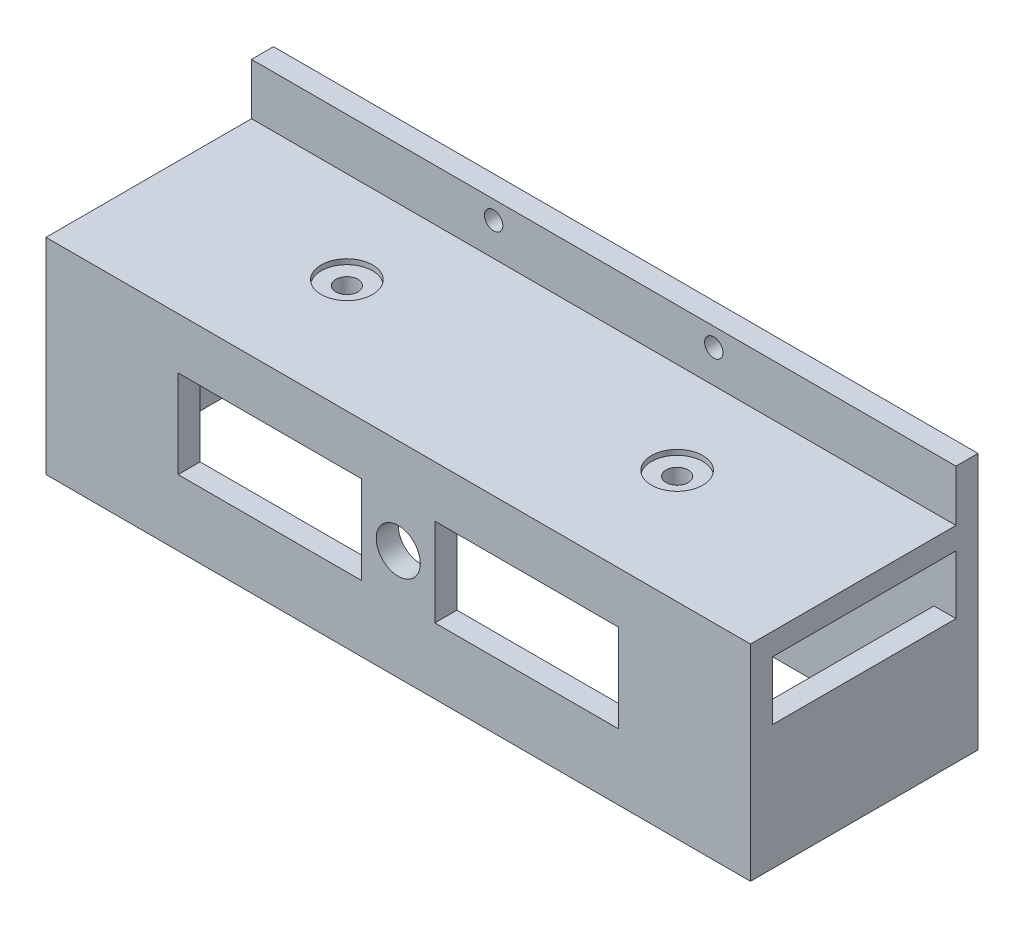
from build123d import *

# Parameters (mm, degrees)
SKETCH1_W           = 96
SKETCH1_H           = 28
BOSS_EXTRUDE1_DEPTH = 3
SKETCH2_W           = 3
SKETCH2_H           = 25
BOSS_EXTRUDE2_DEPTH = 25
SKETCH3_W           = 96
SKETCH3_H           = 35
BOSS_EXTRUDE3_DEPTH = 3
CUT_EXTRUDE2_REACH  = 30
SKETCH4_R           = 1.5
SKETCH5_R           = 3.5
CUT_EXTRUDE3_DEPTH  = 0.7
CUT_EXTRUDE4_REACH  = 33
SKETCH6_R           = 1.5
SKETCH6_R_2         = 1.25
SKETCH7_R           = 4
CUT_EXTRUDE5_DEPTH  = 2
CUT_EXTRUDE7_REACH  = 33
SKETCH8_R           = 3
SKETCH8_W           = 25
SKETCH8_H           = 12
CUT_EXTRUDE8_REACH  = 5
SKETCH9_W           = 20
SKETCH9_H           = 10
SKETCH9_W_2         = 9
CUT_EXTRUDE9_REACH  = 5
SKETCH10_W          = 25
SKETCH10_H          = 8


with BuildPart() as part:
    # Sketch1 → Boss-Extrude1 (new body)
    with BuildSketch(Plane(origin=(0, 0, 0), x_dir=(1, 0, 0), z_dir=(0, 1, 0))):
        with Locations((2.671135036, -161.861135542)):
            Rectangle(SKETCH1_W, SKETCH1_H)
    extrude(amount=BOSS_EXTRUDE1_DEPTH)

    # Sketch2 → Boss-Extrude2 (add)
    with BuildSketch(Plane(origin=(0, 0, 0), x_dir=(-1, 0, 0), z_dir=(0, -1, 0))):
        Polygon((-50.671135036, -175.861135542), (45.328864964, -175.861135542), (45.328864964, -172.861135542), (42.328864964, -172.861135542), (-47.671135036, -172.861135542), (-50.671135036, -172.861135542), align=None)
        with Locations((43.828864964, -160.361135542)):
            Rectangle(SKETCH2_W, SKETCH2_H)
        with Locations((-49.171135036, -160.361135542)):
            Rectangle(SKETCH2_W, SKETCH2_H)
    extrude(amount=BOSS_EXTRUDE2_DEPTH)

    # Sketch3 → Boss-Extrude3 (add)
    with BuildSketch(Plane(origin=(0, 0, 147.861135542), x_dir=(-1, 0, 0), z_dir=(0, 0, -1))):
        with Locations((-2.671135036, -7.5)):
            Rectangle(SKETCH3_W, SKETCH3_H)
    extrude(amount=BOSS_EXTRUDE3_DEPTH)

    # Sketch4 → Cut-Extrude2 (cut, up to next)
    with BuildSketch(Plane(origin=(0, 3, 0), x_dir=(1, 0, 0), z_dir=(0, 1, 0)), mode=Mode.PRIVATE) as cut_extrude2_sk1:
        with Locations((-19.828864964, -160.361135542)):
            Circle(SKETCH4_R)
    cut_extrude2_tool1 = extrude(cut_extrude2_sk1.sketch, amount=-CUT_EXTRUDE2_REACH, mode=Mode.PRIVATE) & part.part
    add(cut_extrude2_tool1.solids().sort_by_distance((-19.828865, 3, 160.361136))[0], mode=Mode.SUBTRACT)
    # Sketch4 → Cut-Extrude2 (cut, up to next)
    with BuildSketch(Plane(origin=(0, 3, 0), x_dir=(1, 0, 0), z_dir=(0, 1, 0)), mode=Mode.PRIVATE) as cut_extrude2_sk2:
        with Locations((25.171135036, -160.361135542)):
            Circle(SKETCH4_R)
    cut_extrude2_tool2 = extrude(cut_extrude2_sk2.sketch, amount=-CUT_EXTRUDE2_REACH, mode=Mode.PRIVATE) & part.part
    add(cut_extrude2_tool2.solids().sort_by_distance((25.171135, 3, 160.361136))[0], mode=Mode.SUBTRACT)

    # Sketch5 → Cut-Extrude3 (cut)
    with BuildSketch(Plane(origin=(0, 3, 0), x_dir=(1, 0, 0), z_dir=(0, 1, 0))):
        with Locations((-19.828864964, -160.361135542)):
            Circle(SKETCH5_R)
        with Locations((25.171135036, -160.361135542)):
            Circle(SKETCH5_R)
    extrude(amount=-CUT_EXTRUDE3_DEPTH, mode=Mode.SUBTRACT)

    # Sketch6 → Cut-Extrude4 (cut, up to next)
    with BuildSketch(Plane(origin=(0, 0, 144.861135542), x_dir=(-1, 0, 0), z_dir=(0, 0, -1)), mode=Mode.PRIVATE) as cut_extrude4_sk1:
        with Locations((-18.921135036, -2)):
            Circle(SKETCH6_R)
    cut_extrude4_tool1 = extrude(cut_extrude4_sk1.sketch, amount=-CUT_EXTRUDE4_REACH, mode=Mode.PRIVATE) & part.part
    add(cut_extrude4_tool1.solids().sort_by_distance((18.921135, -2, 144.861136))[0], mode=Mode.SUBTRACT)
    # Sketch6 → Cut-Extrude4 (cut, up to next)
    with BuildSketch(Plane(origin=(0, 0, 144.861135542), x_dir=(-1, 0, 0), z_dir=(0, 0, -1)), mode=Mode.PRIVATE) as cut_extrude4_sk2:
        with Locations((13.578864964, -2)):
            Circle(SKETCH6_R)
    cut_extrude4_tool2 = extrude(cut_extrude4_sk2.sketch, amount=-CUT_EXTRUDE4_REACH, mode=Mode.PRIVATE) & part.part
    add(cut_extrude4_tool2.solids().sort_by_distance((-13.578865, -2, 144.861136))[0], mode=Mode.SUBTRACT)
    # Sketch6 → Cut-Extrude4 (cut, up to next)
    with BuildSketch(Plane(origin=(0, 0, 144.861135542), x_dir=(-1, 0, 0), z_dir=(0, 0, -1)), mode=Mode.PRIVATE) as cut_extrude4_sk3:
        with Locations((12.328864964, 7.5)):
            Circle(SKETCH6_R_2)
    cut_extrude4_tool3 = extrude(cut_extrude4_sk3.sketch, amount=-CUT_EXTRUDE4_REACH, mode=Mode.PRIVATE) & part.part
    add(cut_extrude4_tool3.solids().sort_by_distance((-12.328865, 7.5, 144.861136))[0], mode=Mode.SUBTRACT)
    # Sketch6 → Cut-Extrude4 (cut, up to next)
    with BuildSketch(Plane(origin=(0, 0, 144.861135542), x_dir=(-1, 0, 0), z_dir=(0, 0, -1)), mode=Mode.PRIVATE) as cut_extrude4_sk4:
        with Locations((-17.671135036, 7.5)):
            Circle(SKETCH6_R_2)
    cut_extrude4_tool4 = extrude(cut_extrude4_sk4.sketch, amount=-CUT_EXTRUDE4_REACH, mode=Mode.PRIVATE) & part.part
    add(cut_extrude4_tool4.solids().sort_by_distance((17.671135, 7.5, 144.861136))[0], mode=Mode.SUBTRACT)

    # Sketch7 → Cut-Extrude5 (cut)
    with BuildSketch(Plane.XY.offset(147.861135542)):
        with Locations((18.921135036, -2)):
            Circle(SKETCH7_R)
        with Locations((-13.578864964, -2)):
            Circle(SKETCH7_R)
    extrude(amount=-CUT_EXTRUDE5_DEPTH, mode=Mode.SUBTRACT)

    # Sketch8 → Cut-Extrude7 (cut, up to next)
    with BuildSketch(Plane.XY.offset(175.861135542), mode=Mode.PRIVATE) as cut_extrude7_sk1:
        with Locations((2.671135036, -10)):
            Circle(SKETCH8_R)
    cut_extrude7_tool1 = extrude(cut_extrude7_sk1.sketch, amount=-CUT_EXTRUDE7_REACH, mode=Mode.PRIVATE) & part.part
    add(cut_extrude7_tool1.solids().sort_by_distance((2.671135, -10, 175.861136))[0], mode=Mode.SUBTRACT)
    # Sketch8 → Cut-Extrude7 (cut, up to next)
    with BuildSketch(Plane.XY.offset(175.861135542), mode=Mode.PRIVATE) as cut_extrude7_sk2:
        with Locations((-14.828864964, -10)):
            Rectangle(SKETCH8_W, SKETCH8_H)
    cut_extrude7_tool2 = extrude(cut_extrude7_sk2.sketch, amount=-CUT_EXTRUDE7_REACH, mode=Mode.PRIVATE) & part.part
    add(cut_extrude7_tool2.solids().sort_by_distance((-14.828865, -10, 175.861136))[0], mode=Mode.SUBTRACT)
    # Sketch8 → Cut-Extrude7 (cut, up to next)
    with BuildSketch(Plane.XY.offset(175.861135542), mode=Mode.PRIVATE) as cut_extrude7_sk3:
        with Locations((20.171135036, -10)):
            Rectangle(SKETCH8_W, SKETCH8_H)
    cut_extrude7_tool3 = extrude(cut_extrude7_sk3.sketch, amount=-CUT_EXTRUDE7_REACH, mode=Mode.PRIVATE) & part.part
    add(cut_extrude7_tool3.solids().sort_by_distance((20.171135, -10, 175.861136))[0], mode=Mode.SUBTRACT)

    # Sketch9 → Cut-Extrude8 (cut, up to next)
    with BuildSketch(Plane.XY.offset(147.861135542), mode=Mode.PRIVATE) as cut_extrude8_sk1:
        with Locations((2.671135036, -12)):
            Rectangle(SKETCH9_W, SKETCH9_H)
    cut_extrude8_tool1 = extrude(cut_extrude8_sk1.sketch, amount=-CUT_EXTRUDE8_REACH, mode=Mode.PRIVATE) & part.part
    add(cut_extrude8_tool1.solids().sort_by_distance((2.671135, -12, 147.861136))[0], mode=Mode.SUBTRACT)
    # Sketch9 → Cut-Extrude8 (cut, up to next)
    with BuildSketch(Plane.XY.offset(147.861135542), mode=Mode.PRIVATE) as cut_extrude8_sk2:
        with Locations((-23.828864964, -12)):
            Rectangle(SKETCH9_W_2, SKETCH9_H)
    cut_extrude8_tool2 = extrude(cut_extrude8_sk2.sketch, amount=-CUT_EXTRUDE8_REACH, mode=Mode.PRIVATE) & part.part
    add(cut_extrude8_tool2.solids().sort_by_distance((-23.828865, -12, 147.861136))[0], mode=Mode.SUBTRACT)
    # Sketch9 → Cut-Extrude8 (cut, up to next)
    with BuildSketch(Plane.XY.offset(147.861135542), mode=Mode.PRIVATE) as cut_extrude8_sk3:
        with Locations((29.171135036, -12)):
            Rectangle(SKETCH9_W_2, SKETCH9_H)
    cut_extrude8_tool3 = extrude(cut_extrude8_sk3.sketch, amount=-CUT_EXTRUDE8_REACH, mode=Mode.PRIVATE) & part.part
    add(cut_extrude8_tool3.solids().sort_by_distance((29.171135, -12, 147.861136))[0], mode=Mode.SUBTRACT)

    # Sketch10 → Cut-Extrude9 (cut, up to next)
    with BuildSketch(Plane.ZY.offset(-47.671135036), mode=Mode.PRIVATE) as cut_extrude9_sk1:
        with Locations((160.361135542, -4)):
            Rectangle(SKETCH10_W, SKETCH10_H)
    cut_extrude9_tool1 = extrude(cut_extrude9_sk1.sketch, amount=-CUT_EXTRUDE9_REACH, mode=Mode.PRIVATE) & part.part
    add(cut_extrude9_tool1.solids().sort_by_distance((47.671135, -4, 160.361136))[0], mode=Mode.SUBTRACT)


solid = part.part
